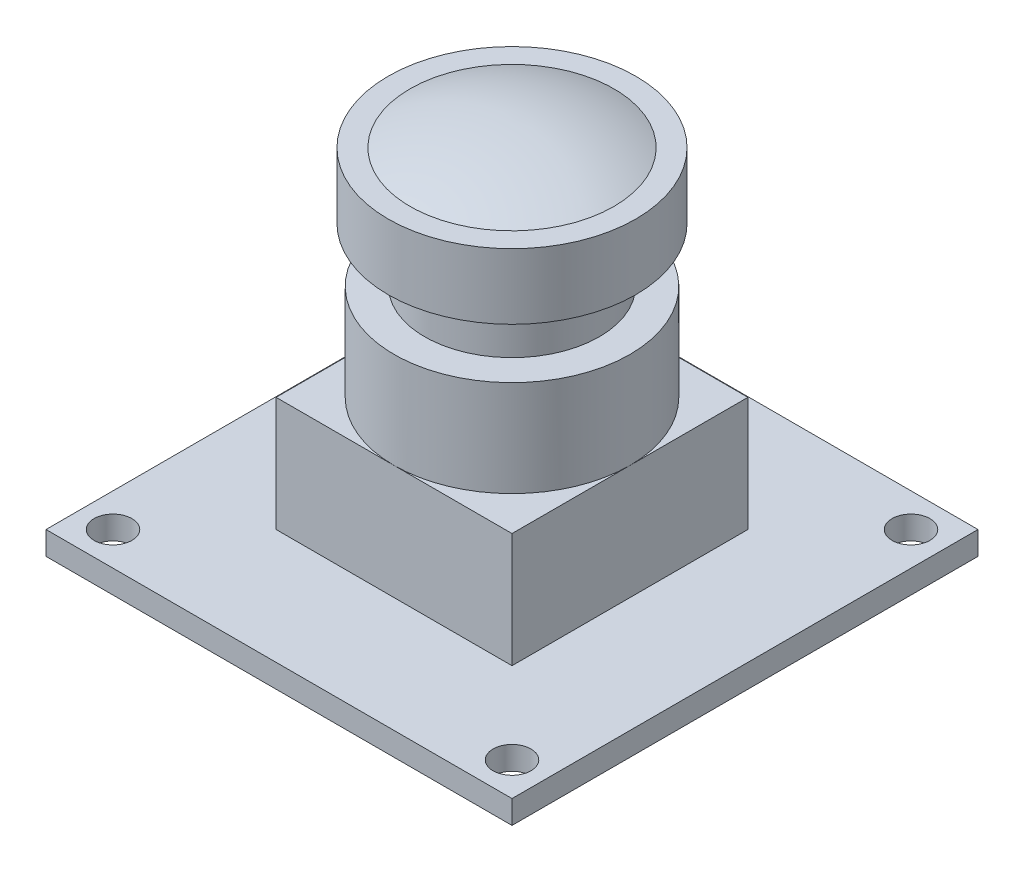
from build123d import *

# Parameters (mm, degrees)
SKETCH1_W           = 32
SKETCH1_H           = 32
SKETCH1_R           = 1.3
BOSS_EXTRUDE1_DEPTH = 1.6
SKETCH2_W           = 16.2
SKETCH2_H           = 16.2
BOSS_EXTRUDE2_DEPTH = 7.86


with BuildPart() as part:
    # Sketch1 → Boss-Extrude1 (new body)
    with BuildSketch(Plane(origin=(0, 0, 0), x_dir=(1, 0, 0), z_dir=(0, 1, 0))):
        Rectangle(SKETCH1_W, SKETCH1_H)
        with Locations((-13.7, 13.7)):
            Circle(SKETCH1_R, mode=Mode.SUBTRACT)
        with Locations((13.7, 13.7)):
            Circle(SKETCH1_R, mode=Mode.SUBTRACT)
        with Locations((13.7, -13.7)):
            Circle(SKETCH1_R, mode=Mode.SUBTRACT)
        with Locations((-13.7, -13.7)):
            Circle(SKETCH1_R, mode=Mode.SUBTRACT)
    extrude(amount=BOSS_EXTRUDE1_DEPTH)

    # Sketch2 → Boss-Extrude2 (add)
    with BuildSketch(Plane(origin=(0, 1.6, 0), x_dir=(1, 0, 0), z_dir=(0, 1, 0))):
        Rectangle(SKETCH2_W, SKETCH2_H)
    extrude(amount=BOSS_EXTRUDE2_DEPTH)

    # Sketch4 → Revolve3 (revolve)
    with BuildSketch(Plane.XY):
        Polygon((0, 9.46), (0, 24.31), (8.5, 24.31), (8.5, 19.81), (6, 19.81), (6, 16.06), (8.1, 16.06), (8.1, 9.46), align=None)
        with BuildLine():
            Line((0, 25.81), (0, 24.31))
            Line((0, 24.31), (7, 24.31))
            ThreePointArc((7, 24.31), (3.579455266, 25.43079124), (0, 25.81))
        make_face()
    revolve(axis=Axis((0, 9.46, 0), (0, 1, 0)))


solid = part.part
